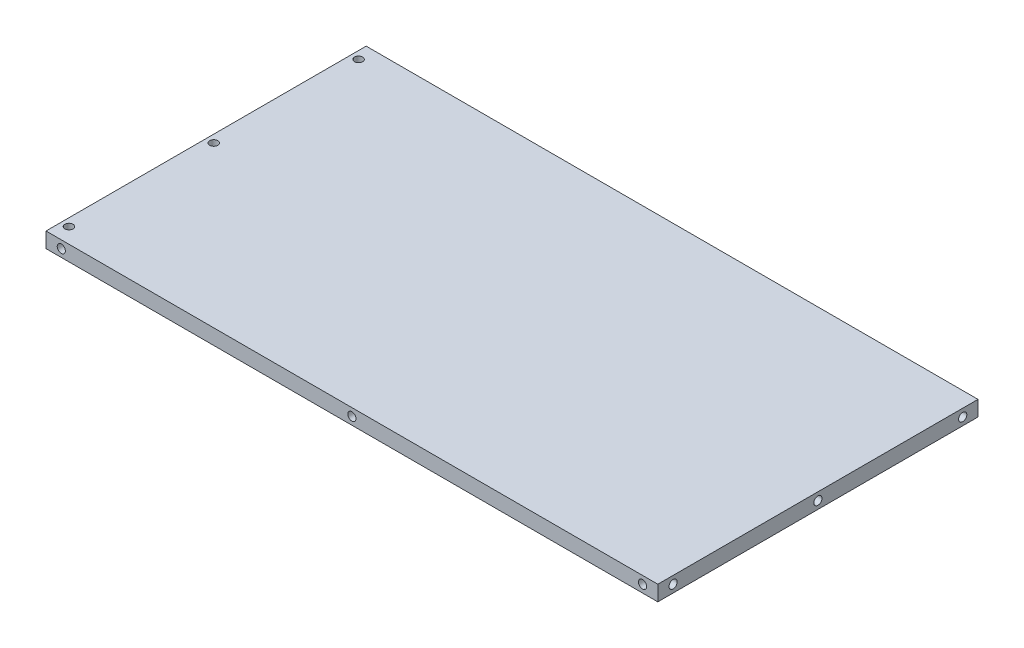
from build123d import *

# Parameters (mm, degrees)
SKETCH1_W               = 600
SKETCH1_H               = 314
BOSS_EXTRUDE1_DEPTH     = 15
SKETCH2_R               = 4
CUT_EXTRUDE1_DEPTH      = 10
LPATTERN1_COUNT         = 3
LPATTERN1_PITCH         = 142
SKETCH3_R               = 4
CUT_EXTRUDE2_DEPTH      = 10
LPATTERN2_COUNT         = 3
LPATTERN2_PITCH         = 285
SKETCH4_R               = 4
CUT_EXTRUDE3_DEPTH      = 10
LPATTERN3_COUNT         = 3
LPATTERN3_PITCH         = 142
MIRROR1_COPY_1_SKETCH_R = 4
MIRROR1_COPY_1_DEPTH    = 10
MIRROR1_COPY_2_SKETCH_R = 4
MIRROR1_COPY_2_DEPTH    = 10


with BuildPart() as part:
    # Sketch1 → Boss-Extrude1 (new body)
    with BuildSketch(Plane(origin=(0, 0, 0), x_dir=(1, 0, 0), z_dir=(0, 1, 0))):
        Rectangle(SKETCH1_W, SKETCH1_H)
    extrude(amount=BOSS_EXTRUDE1_DEPTH)

    # Sketch2 → Cut-Extrude1 (cut)
    with BuildSketch(Plane(origin=(0, 15, 0), x_dir=(1, 0, 0), z_dir=(0, 1, 0))):
        with Locations((-292.5, 142)):
            Circle(SKETCH2_R)
    cut_extrude1 = extrude(amount=-CUT_EXTRUDE1_DEPTH, mode=Mode.SUBTRACT)

    # LPattern1: Cut-Extrude1 ×3
    with Locations(*[(0, 0, i * LPATTERN1_PITCH) for i in range(1, LPATTERN1_COUNT)]):
        add(cut_extrude1, mode=Mode.SUBTRACT)

    # Sketch3 → Cut-Extrude2 (cut)
    with BuildSketch(Plane.XY.offset(157)):
        with Locations((-285, 7.5)):
            Circle(SKETCH3_R)
    cut_extrude2 = extrude(amount=-CUT_EXTRUDE2_DEPTH, mode=Mode.SUBTRACT)

    # LPattern2: Cut-Extrude2 ×3
    with Locations(*[(i * LPATTERN2_PITCH, 0, 0) for i in range(1, LPATTERN2_COUNT)]):
        add(cut_extrude2, mode=Mode.SUBTRACT)

    # Sketch4 → Cut-Extrude3 (cut)
    with BuildSketch(Plane(origin=(300, 0, 0), x_dir=(0, 0, -1), z_dir=(1, 0, 0))):
        with Locations((-142, 7.5)):
            Circle(SKETCH4_R)
    cut_extrude3 = extrude(amount=-CUT_EXTRUDE3_DEPTH, mode=Mode.SUBTRACT)

    # LPattern3: Cut-Extrude3 ×3
    with Locations(*[(0, 0, -i * LPATTERN3_PITCH) for i in range(1, LPATTERN3_COUNT)]):
        add(cut_extrude3, mode=Mode.SUBTRACT)

    # Mirror1: Cut-Extrude2 across plane
    add(cut_extrude2.mirror(Plane.XY), mode=Mode.SUBTRACT)

    # Mirror1 copy 1 sketch → Mirror1 copy 1 (cut)
    with BuildSketch(Plane(origin=(285, 0, -157), x_dir=(1, 0, 0), z_dir=(0, 0, -1))):
        with Locations((-285, -7.5)):
            Circle(MIRROR1_COPY_1_SKETCH_R)
    extrude(amount=-MIRROR1_COPY_1_DEPTH, mode=Mode.SUBTRACT)

    # Mirror1 copy 2 sketch → Mirror1 copy 2 (cut)
    with BuildSketch(Plane(origin=(570, 0, -157), x_dir=(1, 0, 0), z_dir=(0, 0, -1))):
        with Locations((-285, -7.5)):
            Circle(MIRROR1_COPY_2_SKETCH_R)
    extrude(amount=-MIRROR1_COPY_2_DEPTH, mode=Mode.SUBTRACT)


solid = part.part
